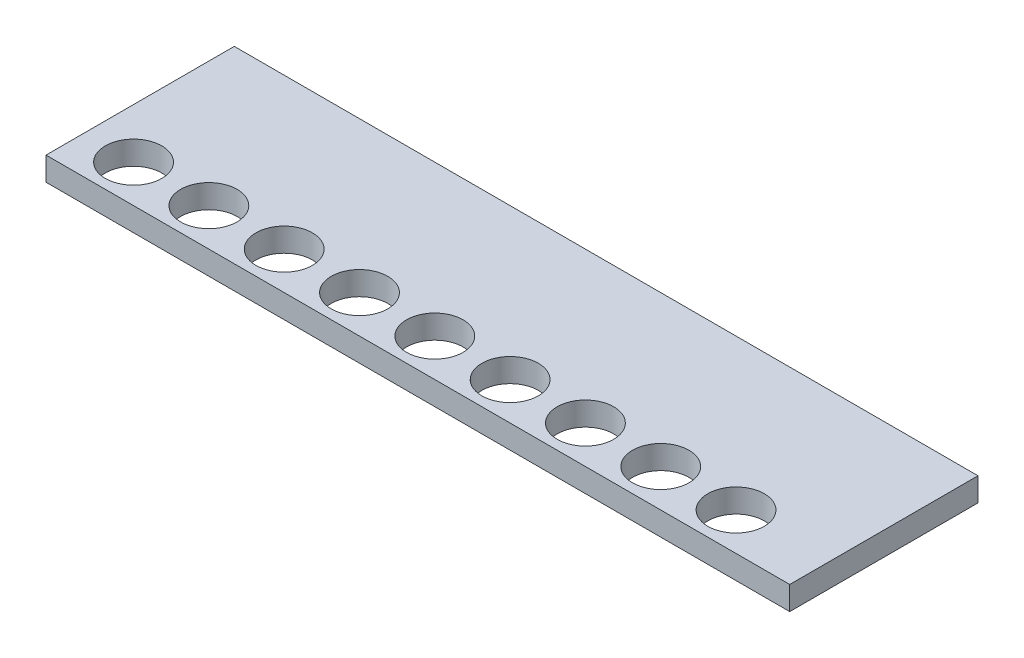
from build123d import *

# Parameters (mm, degrees)
SKETCH2_W           = 100.33
SKETCH2_H           = 25.4
BOSS_EXTRUDE1_DEPTH = 3.175
SKETCH3_R           = 3.81
CUT_EXTRUDE1_DEPTH  = 4.175


with BuildPart() as part:
    # Sketch2 → Boss-Extrude1 (new body)
    with BuildSketch(Plane(origin=(0, 0, 0), x_dir=(1, 0, 0), z_dir=(0, 1, 0))):
        Rectangle(SKETCH2_W, SKETCH2_H)
    extrude(amount=BOSS_EXTRUDE1_DEPTH)

    # Sketch3 → Cut-Extrude1 (cut, through all)
    with BuildSketch(Plane(origin=(0, 3.175, 0), x_dir=(1, 0, 0), z_dir=(0, 1, 0))):
        with Locations((-43.434, -7.62)):
            Circle(SKETCH3_R)
        with Locations((-33.274, -7.62)):
            Circle(SKETCH3_R)
        with Locations((-23.114, -7.62)):
            Circle(SKETCH3_R)
        with Locations((-12.954, -7.62)):
            Circle(SKETCH3_R)
        with Locations((-2.794, -7.62)):
            Circle(SKETCH3_R)
        with Locations((7.366, -7.62)):
            Circle(SKETCH3_R)
        with Locations((17.526, -7.62)):
            Circle(SKETCH3_R)
        with Locations((27.686, -7.62)):
            Circle(SKETCH3_R)
        with Locations((37.846, -7.62)):
            Circle(SKETCH3_R)
    extrude(amount=-CUT_EXTRUDE1_DEPTH, mode=Mode.SUBTRACT)


solid = part.part
